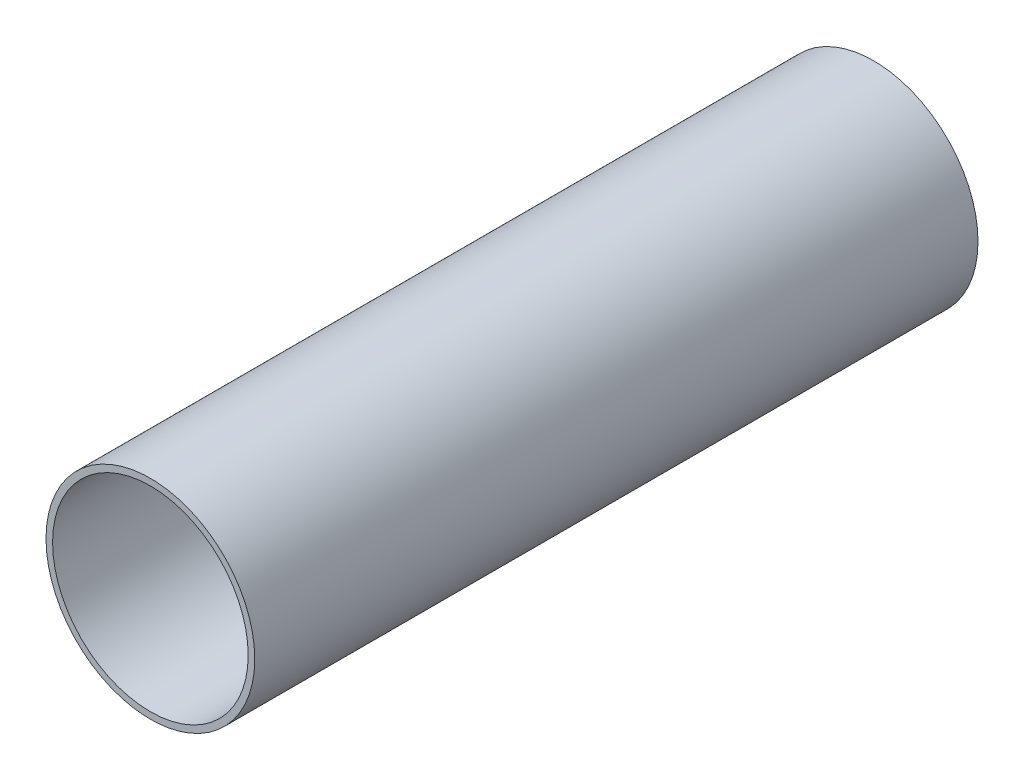
from build123d import *

# Parameters (mm, degrees)
SKETCH1_R           = 31.75
SKETCH1_R_2         = 29.75
BOSS_EXTRUDE1_DEPTH = 220


with BuildPart() as part:
    # Sketch1 → Boss-Extrude1 (new body)
    with BuildSketch(Plane.XY):
        Circle(SKETCH1_R)
        Circle(SKETCH1_R_2, mode=Mode.SUBTRACT)
    extrude(amount=BOSS_EXTRUDE1_DEPTH)


solid = part.part
